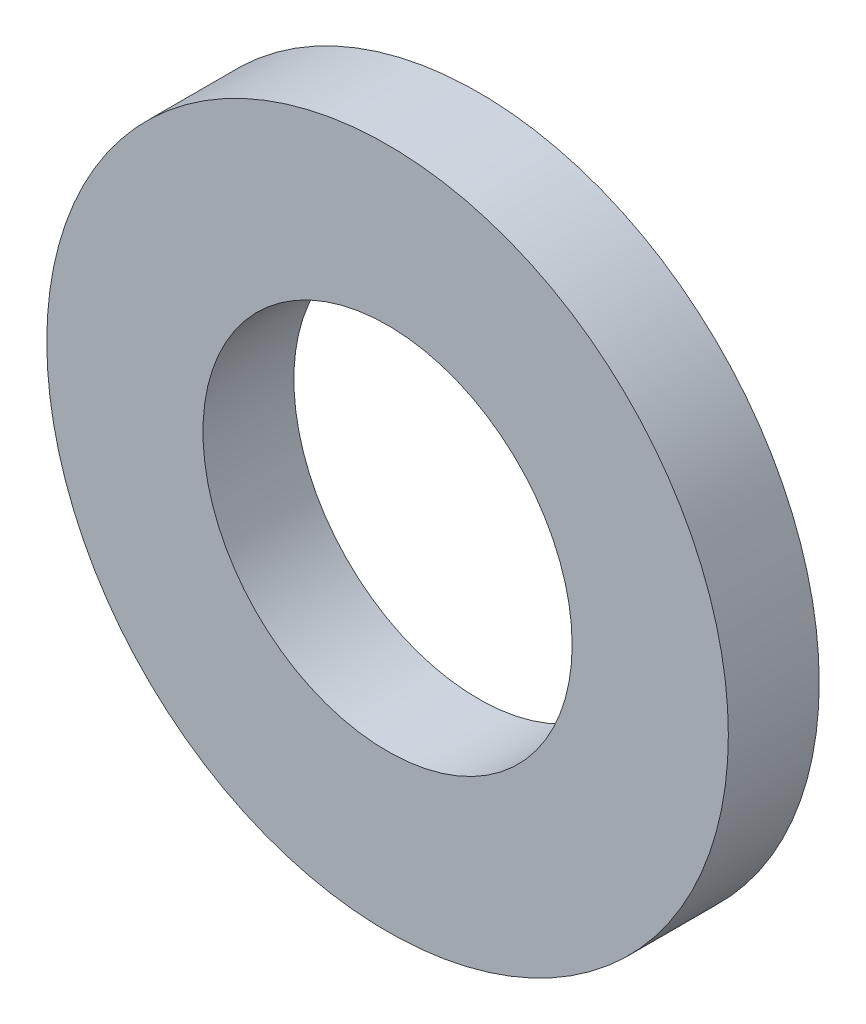
from build123d import *

# Parameters (mm, degrees)
ESQUISSE1_R        = 6
ESQUISSE1_R_2      = 3.25
BOSS_EXTRU_1_DEPTH = 0.8


with BuildPart() as part:
    # Esquisse1 → Boss.-Extru.1 (new body, symmetric)
    with BuildSketch(Plane.XY):
        Circle(ESQUISSE1_R)
        Circle(ESQUISSE1_R_2, mode=Mode.SUBTRACT)
    extrude(amount=BOSS_EXTRU_1_DEPTH, both=True)


solid = part.part
